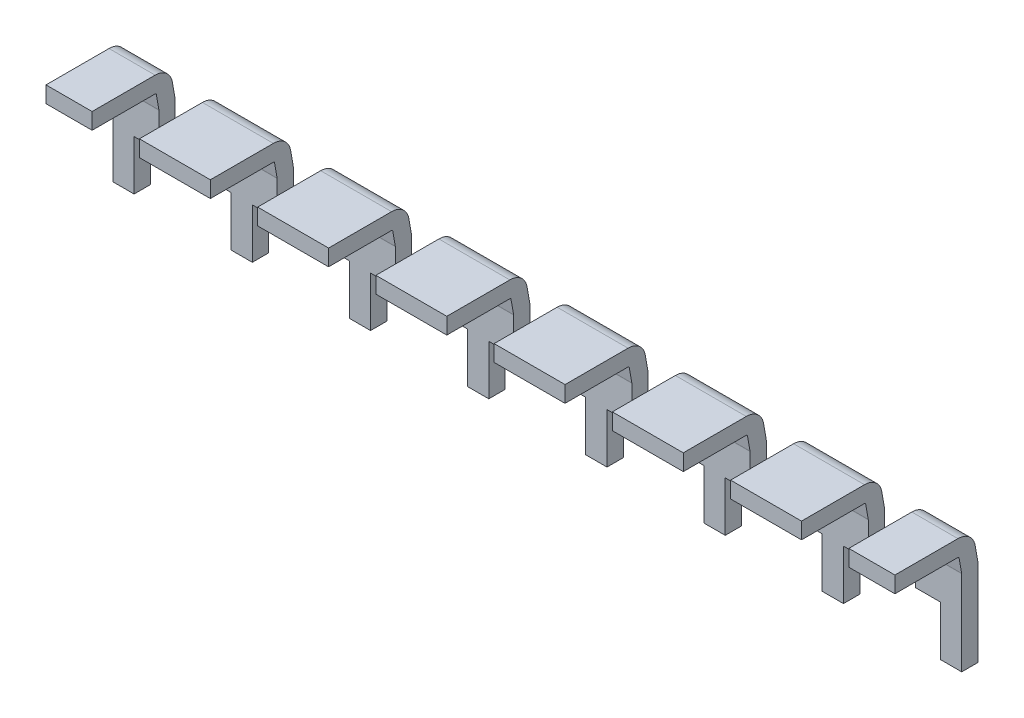
from build123d import *

# Parameters (mm, degrees)
SKETCH1_W      = 1.524
SKETCH1_H      = 0.35
SKETCH1_W_2    = 0.9906
SKETCH10_W     = 0.5334
SKETCH10_H     = 1.114856468
EXTRUDE1_DEPTH = 3.08092137


with BuildPart() as part:
    # Sweep11: sweep along a path in Sketch2
    with BuildLine(Plane(origin=(0, 0, 0), x_dir=(0, 0, -1), z_dir=(1, 0, 0))) as sweep11_path:
        Line((0, 0), (1.354016583, 0))
        ThreePointArc((1.354016583, 0), (1.482574105, -0.046791111), (1.550978134, -0.165270364))
        Line((1.550978134, -0.165270364), (1.606961551, -0.482768097))
        ThreePointArc((1.606961551, -0.482768097), (1.60923894, -0.500066584), (1.61, -0.517497733))
        Line((1.61, -0.517497733), (1.61, -2.345))
    # Sketch1 → Sweep11 (sweep)
    with BuildSketch(Plane.XY):
        with Locations((-1.27, 0)):
            Rectangle(SKETCH1_W, SKETCH1_H)
        with Locations((6.35, 0)):
            Rectangle(SKETCH1_W, SKETCH1_H)
        with Locations((8.6233, 0)):
            Rectangle(SKETCH1_W_2, SKETCH1_H)
        with Locations((-8.6233, 0)):
            Rectangle(SKETCH1_W_2, SKETCH1_H)
        with Locations((-3.81, 0)):
            Rectangle(SKETCH1_W, SKETCH1_H)
        with Locations((-6.35, 0)):
            Rectangle(SKETCH1_W, SKETCH1_H)
        with Locations((1.27, 0)):
            Rectangle(SKETCH1_W, SKETCH1_H)
        with Locations((3.81, 0)):
            Rectangle(SKETCH1_W, SKETCH1_H)
    sweep(path=sweep11_path.line)

    # Sketch10 → Extrude1 (cut, through all)
    with BuildSketch(Plane(origin=(0, 0.290637802, -1.648288881), x_dir=(-1, 0, 0), z_dir=(0, 0.173648178, -0.984807753))):
        with Locations((-8.3947, -2.061907944)):
            Rectangle(SKETCH10_W, SKETCH10_H)
        with Locations((-6.8453, -2.061907944)):
            Rectangle(SKETCH10_W, SKETCH10_H)
        with Locations((-5.8547, -2.061907944)):
            Rectangle(SKETCH10_W, SKETCH10_H)
        with Locations((-4.3053, -2.061907944)):
            Rectangle(SKETCH10_W, SKETCH10_H)
        with Locations((-3.3147, -2.061907944)):
            Rectangle(SKETCH10_W, SKETCH10_H)
        with Locations((8.3947, -2.061907944)):
            Rectangle(SKETCH10_W, SKETCH10_H)
        with Locations((-1.7653, -2.061907944)):
            Rectangle(SKETCH10_W, SKETCH10_H)
        with Locations((-0.7747, -2.061907944)):
            Rectangle(SKETCH10_W, SKETCH10_H)
        with Locations((0.7747, -2.061907944)):
            Rectangle(SKETCH10_W, SKETCH10_H)
        with Locations((1.7653, -2.061907944)):
            Rectangle(SKETCH10_W, SKETCH10_H)
        with Locations((3.3147, -2.061907944)):
            Rectangle(SKETCH10_W, SKETCH10_H)
        with Locations((4.3053, -2.061907944)):
            Rectangle(SKETCH10_W, SKETCH10_H)
        with Locations((5.8547, -2.061907944)):
            Rectangle(SKETCH10_W, SKETCH10_H)
        with Locations((6.8453, -2.061907944)):
            Rectangle(SKETCH10_W, SKETCH10_H)
    extrude(amount=-EXTRUDE1_DEPTH, mode=Mode.SUBTRACT)


solid = part.part
